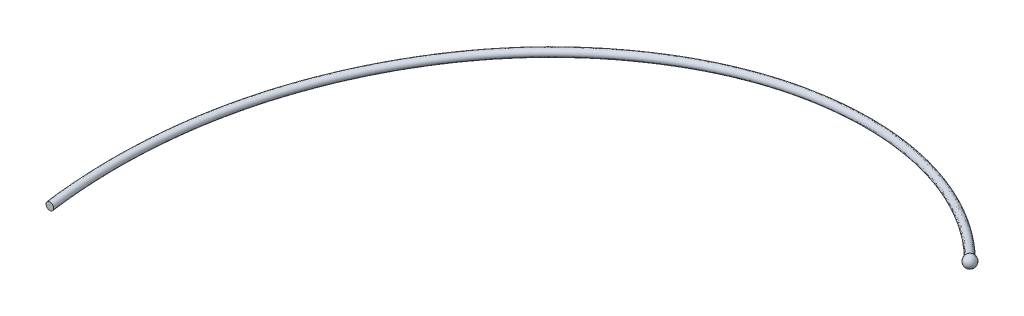
from build123d import *

# Parameters (mm, degrees)
SWEEP1_PITCH       = 5
SWEEP1_HEIGHT      = 1.875
SWEEP1_RADIUS      = 5
SWEEP1_START_ANGLE = -90
SKETCH4_R          = 0.05


with BuildPart() as part:
    # Sweep1: sweep along a helix
    with BuildLine() as sweep1_path:
        add(Helix(SWEEP1_PITCH, SWEEP1_HEIGHT, SWEEP1_RADIUS, center=(0, 0, 0), direction=(0, 1, 0), lefthand=True, mode=Mode.PRIVATE).rotate(Axis((0, 0, 0), (0, 1, 0)), SWEEP1_START_ANGLE))
    # Sketch4 → Sweep1 (sweep)
    with BuildSketch(Plane.XY):
        with Locations((-5, 0)):
            Circle(SKETCH4_R)
    sweep(path=sweep1_path.line, is_frenet=True)


with BuildPart() as body_2:
    # Sketch6 → Revolve4 (revolve)
    with BuildSketch(Plane(origin=(0, 0, 0), x_dir=(0.707106781, 0, -0.707106781), z_dir=(0.707106781, 0, 0.707106781))):
        with BuildLine():
            Line((5, 1.8), (5, 1.95))
            ThreePointArc((5, 1.95), (4.925, 1.875), (5, 1.8))
        make_face()
    revolve(axis=Axis((3.535533906, -998.125, -3.535533906), (0, 1, 0)))


solid = Compound([part.part, body_2.part])
